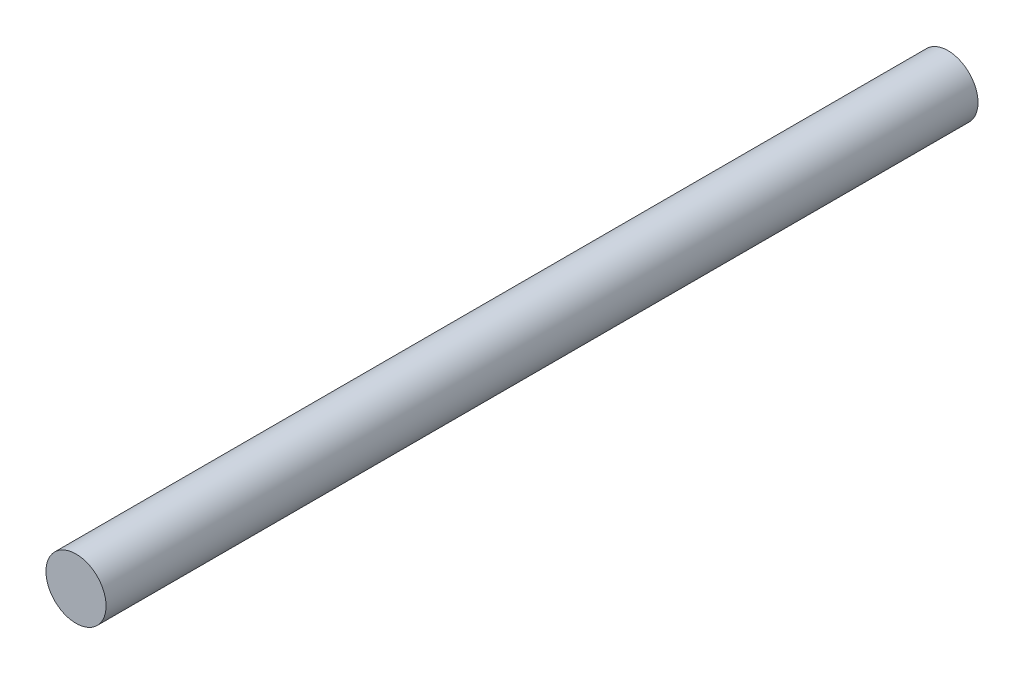
from build123d import *

# Parameters (mm, degrees)
SKETCH_1_R      = 5
EXTRUDE_1_DEPTH = 145


with BuildPart() as part:
    # ｽｹｯﾁ1 → ﾎﾞｽ - 押し出し1 (new body)
    with BuildSketch(Plane.XY):
        Circle(SKETCH_1_R)
    extrude(amount=EXTRUDE_1_DEPTH)


solid = part.part
